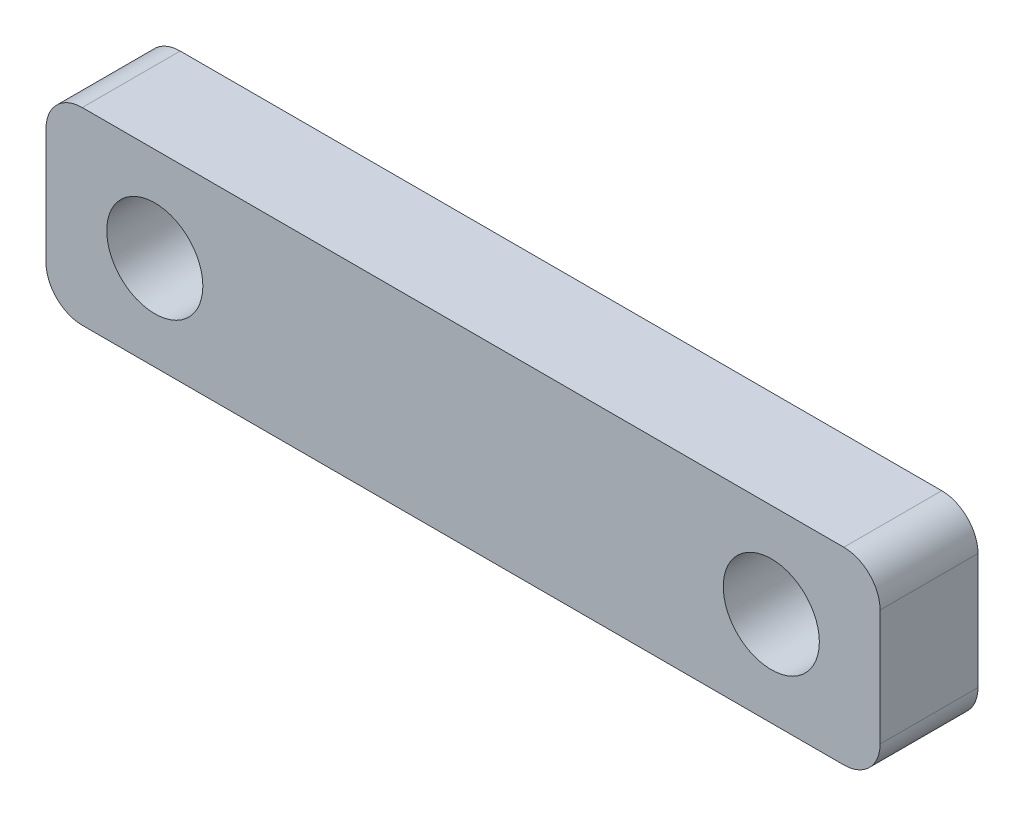
from build123d import *

# Parameters (mm, degrees)
SKETCH2_W           = 23
SKETCH2_H           = 5.2
SKETCH2_R           = 1.325
BOSS_EXTRUDE1_DEPTH = 2.7
FILLET1_R           = 1


with BuildPart() as part:
    # Sketch2 → Boss-Extrude1 (new body)
    with BuildSketch(Plane.XY):
        Rectangle(SKETCH2_W, SKETCH2_H)
        with Locations((-8.5, 0)):
            Circle(SKETCH2_R, mode=Mode.SUBTRACT)
        with Locations((8.5, 0)):
            Circle(SKETCH2_R, mode=Mode.SUBTRACT)
    extrude(amount=BOSS_EXTRUDE1_DEPTH)

    # Fillet1
    fillet1_edges = [part.edges().sort_by_distance(p)[0] for p in [
        (11.5, -2.6, 1.35),
        (-11.5, -2.6, 1.35),
        (-11.5, 2.6, 1.35),
        (11.5, 2.6, 1.35),
    ]]
    fillet(fillet1_edges, radius=FILLET1_R)


solid = part.part
